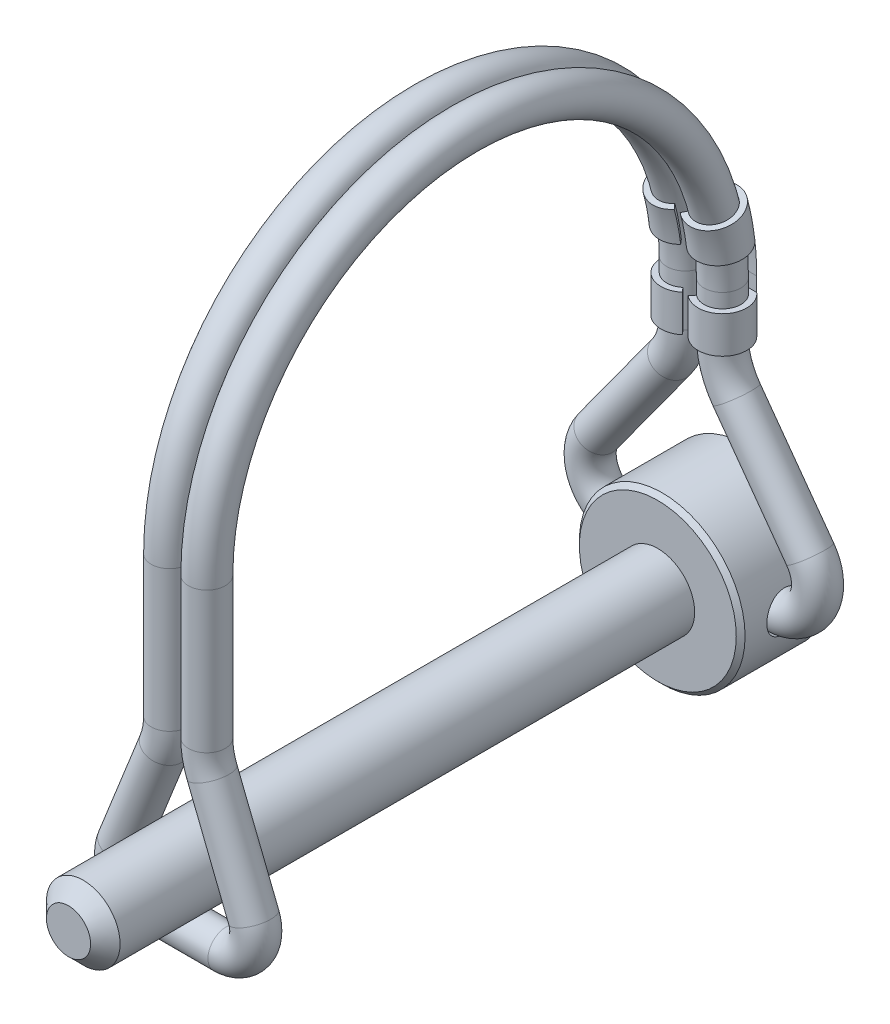
from build123d import *

# Parameters (mm, degrees)
CUT_EXTRUDE1_DEPTH      = 32.057846105
CUT_EXTRUDE1_DEPTH_BACK = 32.057846105
SKETCH2_R               = 1.7145
SKETCH7_R               = 1.5875
CUT_EXTRUDE2_DEPTH      = 56.782916804
CUT_EXTRUDE2_DEPTH_BACK = 56.782916804


with BuildPart() as part:
    # Sketch1 → Revolve1 (revolve)
    with BuildSketch(Plane(origin=(0, 0, 0), x_dir=(0, 0, -1), z_dir=(1, 0, 0)), mode=Mode.PRIVATE) as revolve1_sk:
        Polygon((-29.36875, 0), (29.36875, 0), (29.36875, 6.76275), (28.98775, 7.14375), (21.81225, 7.14375), (21.43125, 6.76275), (21.43125, 3.175), (-28.09875, 3.175), (-29.36875, 1.905), align=None)
    revolve(revolve1_sk.sketch.rotate(Axis((0, 0, 29.36875), (0, 0, -1)), 90), axis=Axis((0, 0, 29.36875), (0, 0, -1)))

    # Sketch2 → Cut-Extrude1 (cut, two sides: drawn at the far end of the back side and taken through both)
    with BuildSketch(Plane(origin=(0, 0, 0), x_dir=(0, 0, -1), z_dir=(1, 0, 0)).offset(-CUT_EXTRUDE1_DEPTH_BACK)):
        with Locations((25.4, 0)):
            Circle(SKETCH2_R)
    extrude(amount=CUT_EXTRUDE1_DEPTH + CUT_EXTRUDE1_DEPTH_BACK, mode=Mode.SUBTRACT)


with BuildPart() as body_2:
    # Sweep1: sweep along a curve in space
    with BuildLine() as sweep1_path:
        Line((-1.603375, 22.225, -25.4), (-1.603375, 18.4546875, -25.4))
        Line((-1.603375, 18.4546875, -25.4), (-1.603375, 17.8196875, -25.4))
        ThreePointArc((-1.603375, 17.8196875, -25.4), (-1.914218451, 15.85726854, -25.4), (-2.816316157, 14.086977165, -25.4))
        Line((-2.816316157, 14.086977165, -25.4), (-9.159136856, 5.3578125, -25.4))
        ThreePointArc((-9.159136856, 5.3578125, -25.4), (-9.435940922, 1.842481109, -25.4), (-6.429375, 0, -25.4))
        Line((-6.429375, 0, -25.4), (6.429375, 0, -25.4))
        ThreePointArc((6.429375, 0, -25.4), (9.435940922, 1.842481109, -25.4), (9.159136856, 5.3578125, -25.4))
        Line((9.159136856, 5.3578125, -25.4), (2.816316157, 14.086977165, -25.4))
        ThreePointArc((2.816316157, 14.086977165, -25.4), (1.914218451, 15.85726854, -25.4), (1.603375, 17.8196875, -25.4))
        Line((1.603375, 17.8196875, -25.4), (1.603375, 18.4546875, -25.4))
        Line((1.603375, 18.4546875, -25.4), (1.603375, 22.225, -25.4))
        ThreePointArc((1.603375, 22.225, -25.4), (1.603375, 44.45, -3.175), (1.603375, 22.225, 19.05))
        Line((1.603375, 22.225, 19.05), (1.603375, 10.715625, 19.05))
        Line((1.603375, 10.715625, 19.05), (1.603375, 10.080625, 19.05))
        ThreePointArc((1.603375, 10.080625, 19.05), (1.717062181, 8.884421661, 19.05), (2.05405293, 7.731050759, 19.05))
        Line((2.05405293, 7.731050759, 19.05), (5.646554978, -1.289020304, 19.05))
        ThreePointArc((5.646554978, -1.289020304, 19.05), (5.38905918, -3.654408237, 19.05), (3.28682615, -4.76885, 19.05))
        Line((3.28682615, -4.76885, 19.05), (-3.28682615, -4.76885, 19.05))
        ThreePointArc((-3.28682615, -4.76885, 19.05), (-5.38905918, -3.654408237, 19.05), (-5.646554978, -1.289020304, 19.05))
        Line((-5.646554978, -1.289020304, 19.05), (-2.05405293, 7.731050759, 19.05))
        ThreePointArc((-2.05405293, 7.731050759, 19.05), (-1.717062181, 8.884421661, 19.05), (-1.603375, 10.080625, 19.05))
        Line((-1.603375, 10.080625, 19.05), (-1.603375, 10.715625, 19.05))
        Line((-1.603375, 10.715625, 19.05), (-1.603375, 22.225, 19.05))
        ThreePointArc((-1.603375, 22.225, 19.05), (-1.603375, 44.45, -3.175), (-1.603375, 22.225, -25.4))
    # Sketch7 → Sweep1 (sweep)
    with BuildSketch(Plane(origin=(0, 0, 0), x_dir=(0, 0, -1), z_dir=(1, 0, 0))):
        with Locations((25.4, 0)):
            Circle(SKETCH7_R)
    sweep(path=sweep1_path.line)


with BuildPart() as body_3:
    # Sweep2: sweep along a path in Sketch8
    with BuildLine(Plane(origin=(0, 0, 0), x_dir=(0, 0, -1), z_dir=(1, 0, 0))) as sweep2_path:
        Line((25.4, 17.8196875), (25.4, 18.4546875))
        Line((25.4, 18.4546875), (25.4, 22.225))
        ThreePointArc((25.4, 22.225), (25.211691239, 25.112016491), (24.649955976, 27.950110553))
    # Sketch9 → Sweep2 (sweep)
    with BuildSketch(Plane(origin=(0, 17.8196875, 0), x_dir=(-1, 0, 0), z_dir=(0, -1, 0))):
        with BuildLine():
            Line((1.603375, 27.4955), (-1.603375, 27.4955))
            ThreePointArc((-1.603375, 27.4955), (-3.571961191, 24.68181572), (-0.254, 23.796782186))
            Line((-0.254, 23.796782186), (-0.581121212, 24.18544105))
            ThreePointArc((-0.581121212, 24.18544105), (-3.094728175, 24.855921), (-1.603375, 26.9875))
            Line((-1.603375, 26.9875), (1.603375, 26.9875))
            ThreePointArc((1.603375, 26.9875), (3.094728175, 24.855921), (0.581121212, 24.18544105))
            Line((0.581121212, 24.18544105), (0.254, 23.796782186))
            ThreePointArc((0.254, 23.796782186), (3.571961191, 24.68181572), (1.603375, 27.4955))
        make_face()
    sweep(path=sweep2_path.line)

    # Sketch10 → Cut-Extrude2 (cut, two sides: drawn at the far end of the back side and taken through both)
    with BuildSketch(Plane(origin=(0, 0, 0), x_dir=(0, 0, -1), z_dir=(1, 0, 0)).offset(-CUT_EXTRUDE2_DEPTH_BACK)):
        with BuildLine():
            Line((26.9875, 20.9946875), (26.9875, 22.225))
            ThreePointArc((26.9875, 22.225), (26.946634702, 23.619467584), (26.824179068, 25.009148998))
            Line((26.824179068, 25.009148998), (3.175, 22.225))
            Line((3.175, 22.225), (3.175, 20.9946875))
            Line((3.175, 20.9946875), (26.9875, 20.9946875))
        make_face()
    extrude(amount=CUT_EXTRUDE2_DEPTH + CUT_EXTRUDE2_DEPTH_BACK, mode=Mode.SUBTRACT)


solid = Compound([part.part, body_2.part, body_3.part])
